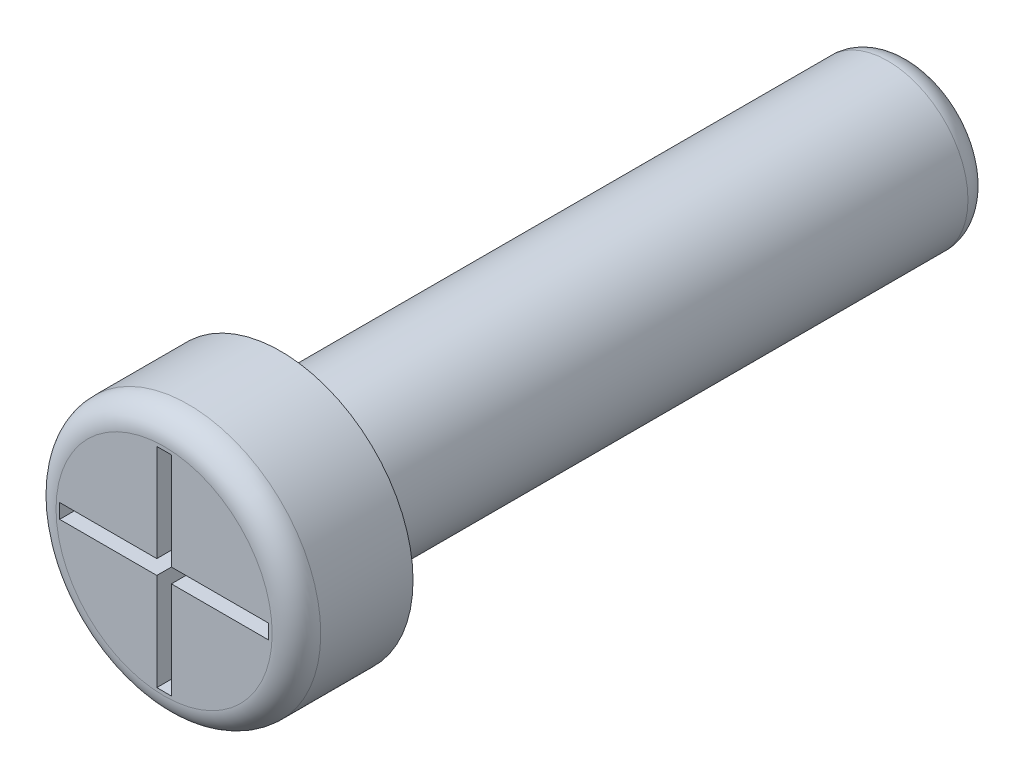
from build123d import *

# Parameters (mm, degrees)
SKICA1_R                 = 2.725
P_IDAT_VYSUNUT_M1_DEPTH  = 2.4
SKICA2_R                 = 1.65
P_IDAT_VYSUNUT_M3_DEPTH  = 13
ODEBRAT_VYSUNUT_M1_DEPTH = 1
ZAOBLIT1_R               = 0.5


with BuildPart() as part:
    # Skica1 → Přidat vysunutím1 (new body)
    with BuildSketch(Plane.XY):
        Circle(SKICA1_R)
    extrude(amount=P_IDAT_VYSUNUT_M1_DEPTH)

    # Skica2 → Přidat vysunutím3 (add)
    with BuildSketch(Plane(origin=(0, 0, 0), x_dir=(-1, 0, 0), z_dir=(0, 0, -1))):
        Circle(SKICA2_R)
    extrude(amount=P_IDAT_VYSUNUT_M3_DEPTH)

    # Skica4 → Odebrat vysunutím1 (cut)
    with BuildSketch(Plane.XY.offset(2.4)):
        Polygon((-0.15, 0.15), (-0.15, 2.15), (0.15, 2.15), (0.15, 0.15), (2.15, 0.15), (2.15, -0.15), (0.15, -0.15), (0.15, -2.15), (-0.15, -2.15), (-0.15, -0.15), (-2.15, -0.15), (-2.15, 0.15), align=None)
    extrude(amount=-ODEBRAT_VYSUNUT_M1_DEPTH, mode=Mode.SUBTRACT)

    # Zaoblit1
    zaoblit1_edges = [part.edges().sort_by_distance(p)[0] for p in [
        (-2.725, 0, 2.4),
        (1.65, 0, -13),
    ]]
    fillet(zaoblit1_edges, radius=ZAOBLIT1_R)


solid = part.part
